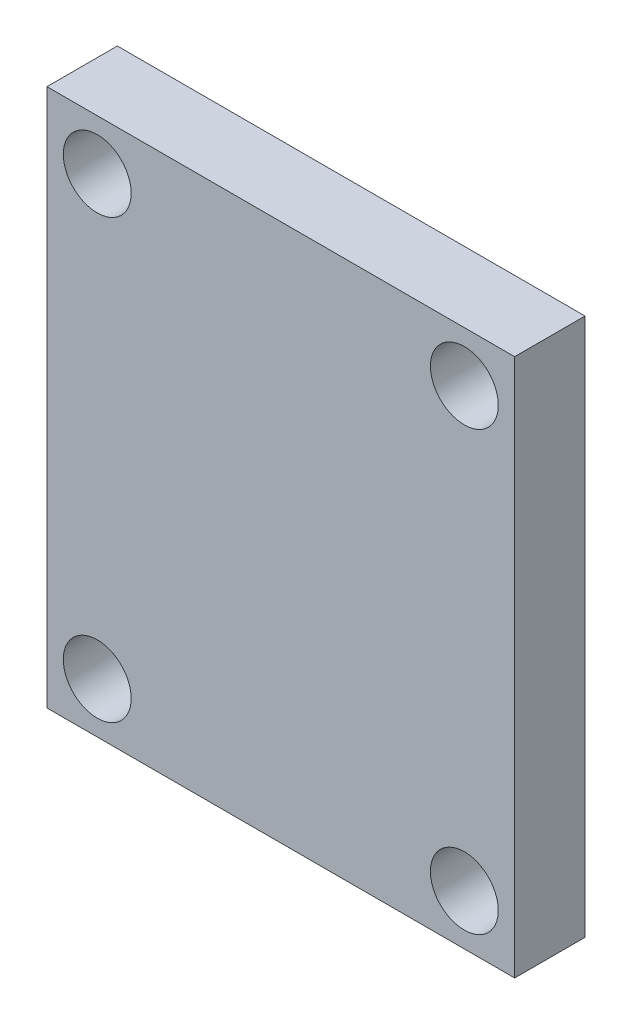
from build123d import *

# Parameters (mm, degrees)
SKICA1_W                 = 93
SKICA1_H                 = 107
P_IDAT_VYSUNUT_M1_DEPTH  = 14
SKICA2_R                 = 6.75
ODEBRAT_VYSUNUT_M1_DEPTH = 15
SKICA4_W                 = 75
SKICA4_H                 = 53
ODEBRAT_VYSUNUT_M2_DEPTH = 0.0001


with BuildPart() as part:
    # Skica1 → Přidat vysunutím1 (new body)
    with BuildSketch(Plane.XY):
        Rectangle(SKICA1_W, SKICA1_H)
    extrude(amount=P_IDAT_VYSUNUT_M1_DEPTH)

    # Skica2 → Odebrat vysunutím1 (cut, through all)
    with BuildSketch(Plane(origin=(0, 0, 0), x_dir=(-1, 0, 0), z_dir=(0, 0, -1))):
        with Locations((-36.5, 43.5)):
            Circle(SKICA2_R)
        with Locations((36.5, 43.5)):
            Circle(SKICA2_R)
        with Locations((36.5, -43.5)):
            Circle(SKICA2_R)
        with Locations((-36.5, -43.5)):
            Circle(SKICA2_R)
    extrude(amount=-ODEBRAT_VYSUNUT_M1_DEPTH, mode=Mode.SUBTRACT)

    # Skica4 → Odebrat vysunutím2 (cut)
    with BuildSketch(Plane(origin=(0, 0, 0), x_dir=(-1, 0, 0), z_dir=(0, 0, -1))):
        Rectangle(SKICA4_W, SKICA4_H)
    extrude(amount=-ODEBRAT_VYSUNUT_M2_DEPTH, mode=Mode.SUBTRACT)


solid = part.part
